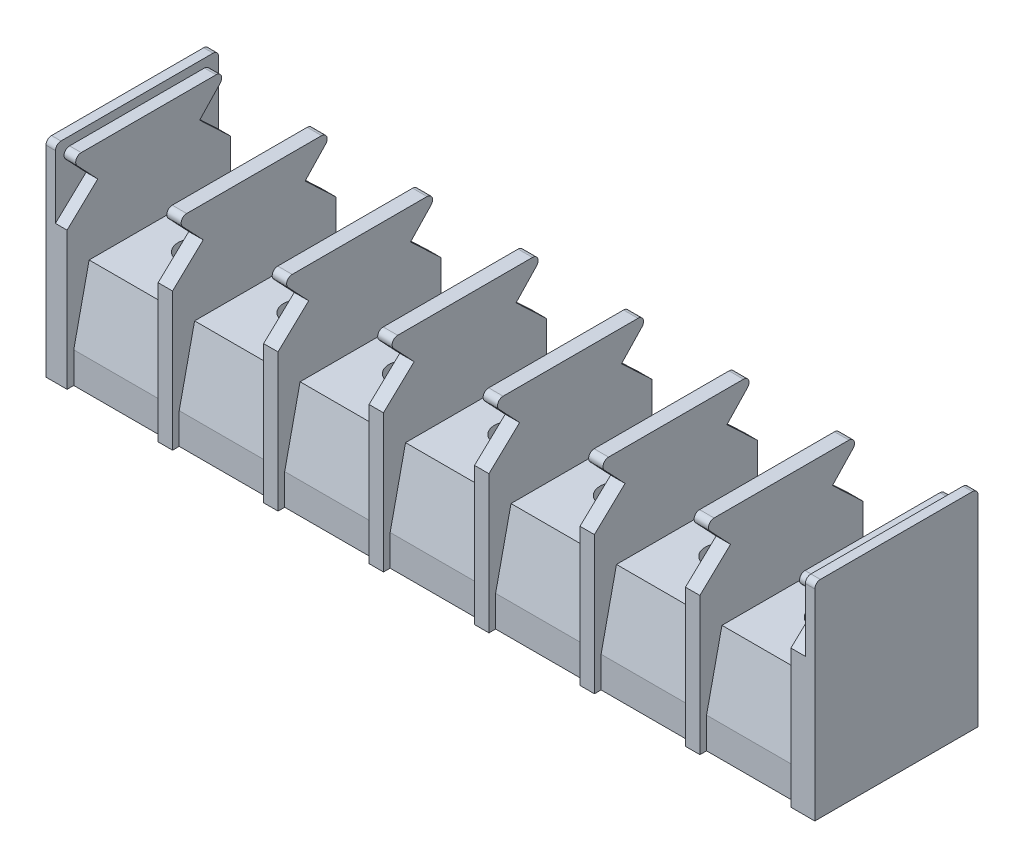
from build123d import *

# Parameters (mm, degrees)
BOSS_EXTRUDE1_DEPTH         = 34.625
BOSS_EXTRUDE2_DEPTH         = 0.85
BOSS_EXTRUDE3_DEPTH         = 1.3
LPATTERN1_COUNT             = 8
LPATTERN1_PITCH             = 9.5
M3_5X0_6_TAPPED_HOLE1_D     = 2.9
M3_5X0_6_TAPPED_HOLE1_DEPTH = 8
M3_5X0_6_TAPPED_HOLE1_TIP   = 0.871247898


with BuildPart() as part:
    # Sketch1 → Boss-Extrude1 (new body, symmetric)
    with BuildSketch(Plane(origin=(0, 0, 0), x_dir=(0, 0, -1), z_dir=(1, 0, 0))):
        Polygon((6.75, 0), (6.75, 2.79), (5.365, 9.1), (-5.365, 9.1), (-6.75, 2.79), (-6.75, 0), align=None)
    extrude(amount=BOSS_EXTRUDE1_DEPTH, both=True)

    # Sketch3 → Boss-Extrude2 (add)
    with BuildSketch(Plane(origin=(34.625, 0, 0), x_dir=(0, 0, -1), z_dir=(1, 0, 0))):
        with BuildLine():
            Line((-6.75, 0), (-7.35, 0))
            Line((-7.35, 0), (-7.35, 18.1))
            ThreePointArc((-7.35, 18.1), (-7.203553391, 18.453553391), (-6.85, 18.6))
            Line((-6.85, 18.6), (6.85, 18.6))
            ThreePointArc((6.85, 18.6), (7.203553391, 18.453553391), (7.35, 18.1))
            Line((7.35, 18.1), (7.35, 0))
            Line((7.35, 0), (6.75, 0))
            Line((6.75, 0), (6.75, 2.79))
            Line((6.75, 2.79), (5.365, 9.1))
            Line((5.365, 9.1), (-5.365, 9.1))
            Line((-5.365, 9.1), (-6.75, 2.79))
            Line((-6.75, 2.79), (-6.75, 0))
        make_face()
    boss_extrude2 = extrude(amount=-BOSS_EXTRUDE2_DEPTH)

    # Mirror1: Boss-Extrude2 across plane
    add(boss_extrude2.mirror(Plane(origin=(0, 0, 0), x_dir=(0, 0, 1), z_dir=(1, 0, 0))))

    # Sketch4 → Boss-Extrude3 (add)
    with BuildSketch(Plane.ZY.offset(-33.775)):
        with BuildLine():
            Line((7.35, 0), (7.35, 12.42))
            Line((7.35, 12.42), (4.588898397, 15.03))
            Line((4.588898397, 15.03), (6.438355915, 16.98652878))
            ThreePointArc((6.438355915, 16.98652878), (6.534203446, 17.527818591), (6.075, 17.83))
            Line((6.075, 17.83), (-6.075, 17.83))
            ThreePointArc((-6.075, 17.83), (-6.534203446, 17.527818591), (-6.438355915, 16.98652878))
            Line((-6.438355915, 16.98652878), (-4.588898397, 15.03))
            Line((-4.588898397, 15.03), (-7.35, 12.42))
            Line((-7.35, 12.42), (-7.35, 0))
            Line((-7.35, 0), (-6.75, 0))
            Line((-6.75, 0), (-6.75, 2.79))
            Line((-6.75, 2.79), (-5.365, 9.1))
            Line((-5.365, 9.1), (5.365, 9.1))
            Line((5.365, 9.1), (6.75, 2.79))
            Line((6.75, 2.79), (6.75, 0))
            Line((6.75, 0), (7.35, 0))
        make_face()
    boss_extrude3 = extrude(amount=BOSS_EXTRUDE3_DEPTH)

    # LPattern1: Boss-Extrude3 ×8
    with Locations(*[(-i * LPATTERN1_PITCH, 0, 0) for i in range(1, LPATTERN1_COUNT)]):
        add(boss_extrude3)

    # M3.5x0.6 Tapped Hole1
    with Locations(Plane(origin=(0, 9.1, 0), x_dir=(1, 0, 0), z_dir=(0, 1, 0))):
        with Locations((-28.625, 0), (-19.125, 0), (0, 0), (-0.125, 0), (9.375, 0), (18.875, 0), (28.375, 0), (-9.625, 0)):
            Hole(M3_5X0_6_TAPPED_HOLE1_D / 2, depth=M3_5X0_6_TAPPED_HOLE1_DEPTH)
            with Locations((0, 0, -(M3_5X0_6_TAPPED_HOLE1_DEPTH + M3_5X0_6_TAPPED_HOLE1_TIP / 2))):  # 118° drill point
                Cone(0, M3_5X0_6_TAPPED_HOLE1_D / 2, M3_5X0_6_TAPPED_HOLE1_TIP, mode=Mode.SUBTRACT)


solid = part.part
